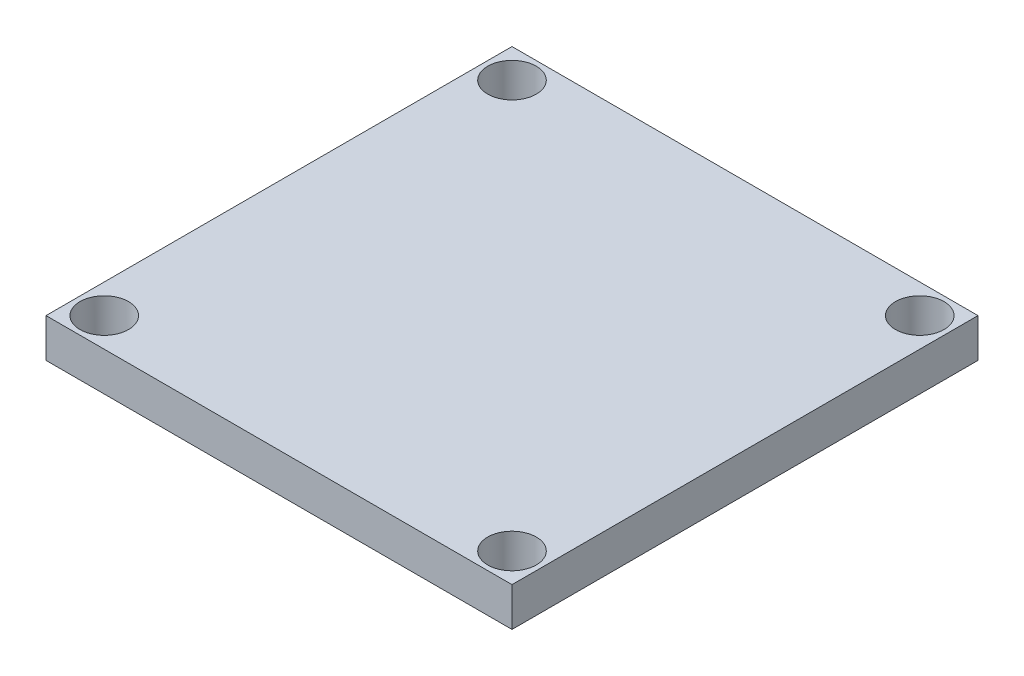
from build123d import *

# Parameters (mm, degrees)
SKETCH2_W           = 24
SKETCH2_H           = 24
BOSS_EXTRUDE1_DEPTH = 2
SKETCH3_R           = 1.25
CUT_EXTRUDE1_DEPTH  = 2


with BuildPart() as part:
    # Sketch2 → Boss-Extrude1 (new body)
    with BuildSketch(Plane(origin=(0, 0, 0), x_dir=(1, 0, 0), z_dir=(0, 1, 0))):
        Rectangle(SKETCH2_W, SKETCH2_H)
    extrude(amount=BOSS_EXTRUDE1_DEPTH)

    # Sketch3 → Cut-Extrude1 (cut)
    with BuildSketch(Plane(origin=(0, 2, 0), x_dir=(1, 0, 0), z_dir=(0, 1, 0))):
        with Locations((-10.5, 10.5)):
            Circle(SKETCH3_R)
        with Locations((10.5, 10.5)):
            Circle(SKETCH3_R)
        with Locations((10.5, -10.5)):
            Circle(SKETCH3_R)
        with Locations((-10.5, -10.5)):
            Circle(SKETCH3_R)
    extrude(amount=-CUT_EXTRUDE1_DEPTH, mode=Mode.SUBTRACT)


solid = part.part
